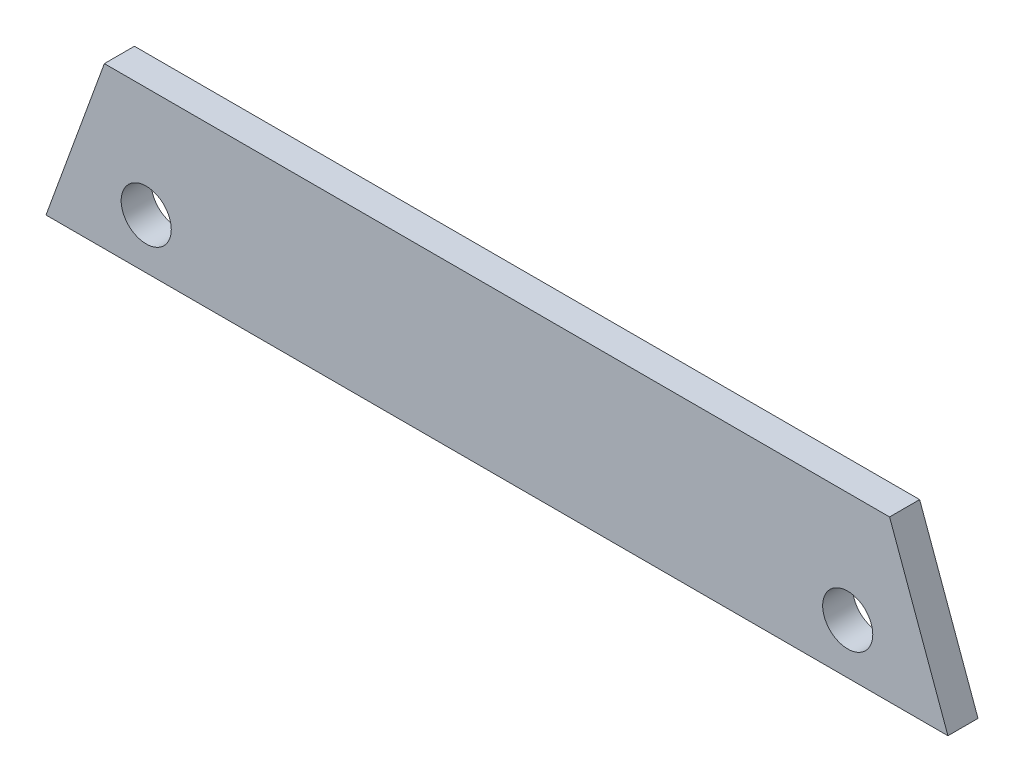
from build123d import *

# Parameters (mm, degrees)
CROQUIS1_R              = 2.5
SALIENTE_EXTRUIR1_DEPTH = 3


with BuildPart() as part:
    # Croquis1 → Saliente-Extruir1 (new body)
    with BuildSketch(Plane.XY):
        Polygon((-45, 0), (45, 0), (39.176476252, 16), (-39.176476252, 16), align=None)
        with Locations((-35, 5)):
            Circle(CROQUIS1_R, mode=Mode.SUBTRACT)
        with Locations((35, 5)):
            Circle(CROQUIS1_R, mode=Mode.SUBTRACT)
    extrude(amount=SALIENTE_EXTRUIR1_DEPTH)


solid = part.part
